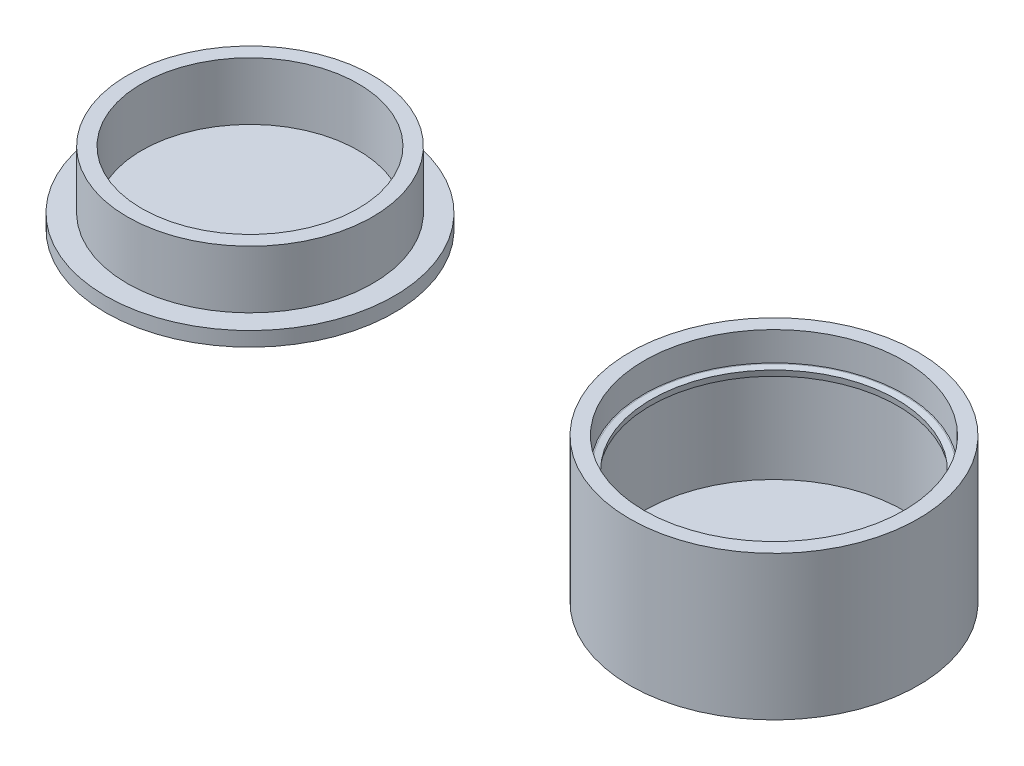
from build123d import *

# Parameters (mm, degrees)
SKETCH1_R             = 20
BOSS_EXTRUDE2_DEPTH   = 20
SKETCH2_R             = 18
CUT_EXTRUDE1_DEPTH    = 4
SKETCH4_R             = 17
CUT_EXTRUDE2_DEPTH    = 1
SKETCH5_R             = 18
CUT_EXTRUDE4_DEPTH    = 13
CHAMFER1_SIZE         = 0.85
CHAMFER1_SIZE2        = 0.149877934
CHAMFER1_PART_2_SIZE  = 0.85
CHAMFER1_PART_2_SIZE2 = 0.149877934
SKETCH6_R             = 20
BOSS_EXTRUDE3_DEPTH   = 2
SKETCH8_R             = 17
SKETCH8_R_2           = 15
BOSS_EXTRUDE5_DEPTH   = 8


with BuildPart() as part:
    # Sketch1 → Boss-Extrude2 (new body)
    with BuildSketch(Plane(origin=(0, 0, 0), x_dir=(1, 0, 0), z_dir=(0, 1, 0))):
        Circle(SKETCH1_R)
    extrude(amount=BOSS_EXTRUDE2_DEPTH)

    # Sketch2 → Cut-Extrude1 (cut)
    with BuildSketch(Plane(origin=(0, 20, 0), x_dir=(1, 0, 0), z_dir=(0, 1, 0))):
        Circle(SKETCH2_R)
    extrude(amount=-CUT_EXTRUDE1_DEPTH, mode=Mode.SUBTRACT)

    # Sketch4 → Cut-Extrude2 (cut)
    with BuildSketch(Plane(origin=(0, 16, 0), x_dir=(1, 0, 0), z_dir=(0, 1, 0))):
        Circle(SKETCH4_R)
    extrude(amount=-CUT_EXTRUDE2_DEPTH, mode=Mode.SUBTRACT)

    # Sketch5 → Cut-Extrude4 (cut)
    with BuildSketch(Plane(origin=(0, 15, 0), x_dir=(1, 0, 0), z_dir=(0, 1, 0))):
        Circle(SKETCH5_R)
    extrude(amount=-CUT_EXTRUDE4_DEPTH, mode=Mode.SUBTRACT)

    # Chamfer1
    chamfer1_edges = [part.edges().sort_by_distance(p)[0] for p in [
        (-17, 16, 0),
    ]]
    chamfer1_side = [part.faces().sort_by_distance(p)[0] for p in [
        (-17.490883118, 16, 0),
    ]]
    chamfer(chamfer1_edges, length=CHAMFER1_SIZE, length2=CHAMFER1_SIZE2, reference=chamfer1_side[0])

    # Chamfer1 part 2
    chamfer1_part_2_edges = [part.edges().sort_by_distance(p)[0] for p in [
        (-17, 15, 0),
    ]]
    chamfer1_part_2_side = [part.faces().sort_by_distance(p)[0] for p in [
        (-17, 15.5, 0),
    ]]
    chamfer(chamfer1_part_2_edges, length=CHAMFER1_PART_2_SIZE, length2=CHAMFER1_PART_2_SIZE2, reference=chamfer1_part_2_side[0])


with BuildPart() as body_2:
    # Sketch6 → Boss-Extrude3 (new body)
    with BuildSketch(Plane(origin=(0, 0, 0), x_dir=(1, 0, 0), z_dir=(0, 1, 0))):
        with Locations((-81.065822517, 8.428593597)):
            Circle(SKETCH6_R)
    extrude(amount=BOSS_EXTRUDE3_DEPTH)

    # Sketch8 → Boss-Extrude5 (add)
    with BuildSketch(Plane(origin=(0, 2, 0), x_dir=(1, 0, 0), z_dir=(0, 1, 0))):
        with Locations((-81.065822517, 8.428593597)):
            Circle(SKETCH8_R)
        with Locations((-81.065822517, 8.428593597)):
            Circle(SKETCH8_R_2, mode=Mode.SUBTRACT)
    extrude(amount=BOSS_EXTRUDE5_DEPTH)


solid = Compound([part.part, body_2.part])
